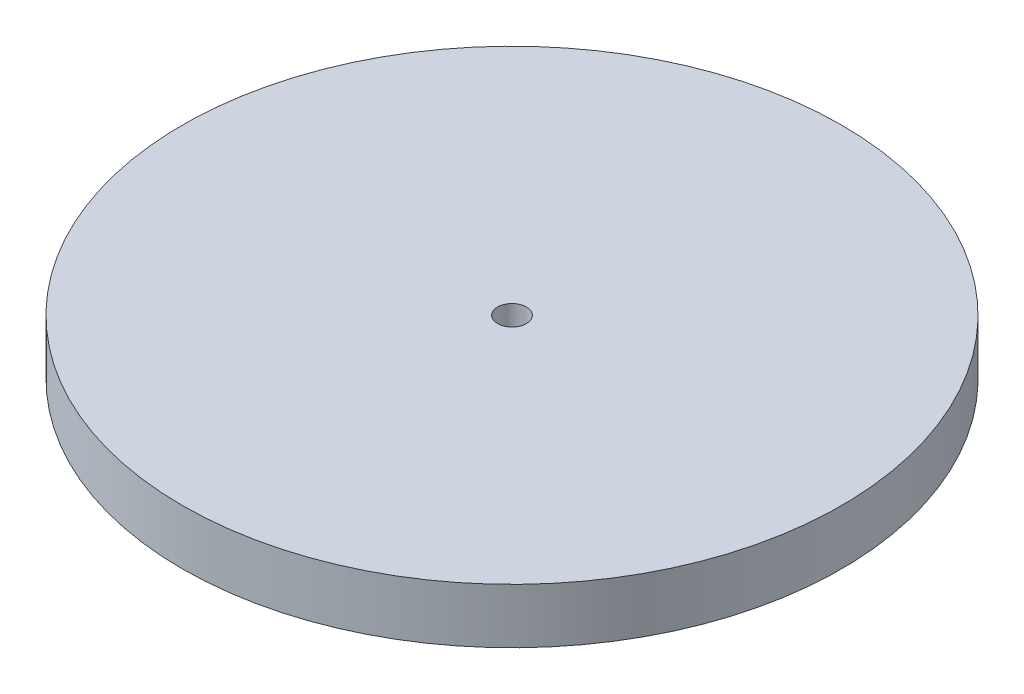
from build123d import *

# Parameters (mm, degrees)
SKETCH1_R           = 45.72
SKETCH1_R_2         = 2
BOSS_EXTRUDE1_DEPTH = 7.62


with BuildPart() as part:
    # Sketch1 → Boss-Extrude1 (new body)
    with BuildSketch(Plane(origin=(0, 0, 0), x_dir=(1, 0, 0), z_dir=(0, 1, 0))):
        Circle(SKETCH1_R)
        Circle(SKETCH1_R_2, mode=Mode.SUBTRACT)
    extrude(amount=BOSS_EXTRUDE1_DEPTH)


solid = part.part
